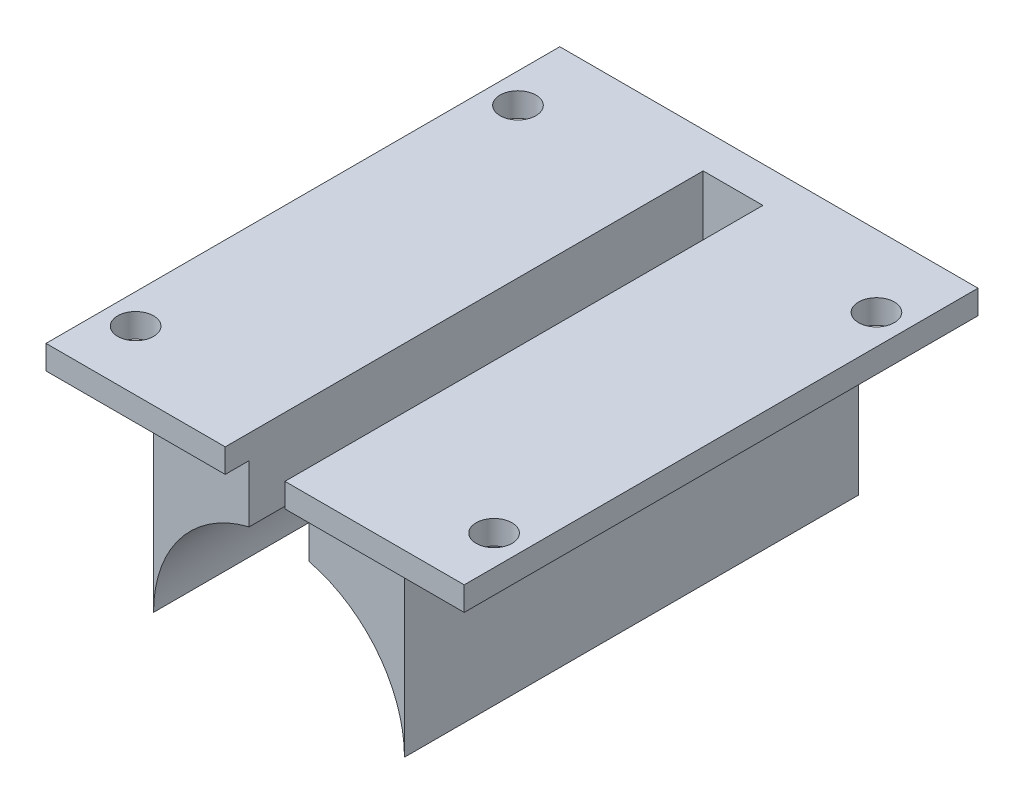
from build123d import *

# Parameters (mm, degrees)
SALIENTE_EXTRUIR1_DEPTH   = 38
SALIENTE_EXTRUIR1_2_DEPTH = 38
CROQUIS2_R                = 1.5
SALIENTE_EXTRUIR2_DEPTH   = 2
SALIENTE_EXTRUIR4_DEPTH   = 17
CROQUIS4_R                = 4
CORTAR_EXTRUIR2_DEPTH     = 17


with BuildPart() as part:
    # Croquis1 → Saliente-Extruir1 (new body)
    with BuildSketch(Plane.XY):
        with BuildLine():
            Line((10.5, 0), (10.5, 10.5))
            Line((10.5, 10.5), (10.5, 17))
            Line((10.5, 17), (2.5, 17))
            Line((2.5, 17), (2.5, 10.198039027))
            ThreePointArc((2.5, 10.198039027), (8.261355821, 6.480740698), (10.5, 0))
        make_face()
    extrude(amount=SALIENTE_EXTRUIR1_DEPTH)



with BuildPart() as body_2:
    # Croquis1 → Saliente-Extruir1 2 (new body)
    with BuildSketch(Plane.XY):
        with BuildLine():
            Line((-10.5, 0), (-10.5, 10.5))
            Line((-10.5, 10.5), (-10.5, 17))
            Line((-10.5, 17), (-2.5, 17))
            Line((-2.5, 17), (-2.5, 10.198039027))
            ThreePointArc((-2.5, 10.198039027), (-8.261355821, 6.480740698), (-10.5, 0))
        make_face()
    extrude(amount=SALIENTE_EXTRUIR1_2_DEPTH)


with BuildPart() as part_1:
    add(part.part)

    add(body_2.part)  # Saliente-Extruir2 merges body 2
    # Croquis2 → Saliente-Extruir2 (add)
    with BuildSketch(Plane(origin=(0, 17, 0), x_dir=(1, 0, 0), z_dir=(0, 1, 0))):
        Polygon((2.5, 0), (-2.5, 0), (-2.5, -40), (-12.5, -40), (-17.5, -40), (-17.5, 2), (-17.5, 3), (17.5, 3), (17.5, 2), (17.5, -40), (12.5, -40), (2.5, -40), align=None)
        with Locations((-15, -3)):
            Circle(CROQUIS2_R, mode=Mode.SUBTRACT)
        with Locations((15, -3)):
            Circle(CROQUIS2_R, mode=Mode.SUBTRACT)
        with Locations((15, -35)):
            Circle(CROQUIS2_R, mode=Mode.SUBTRACT)
        with Locations((-15, -35)):
            Circle(CROQUIS2_R, mode=Mode.SUBTRACT)
    extrude(amount=-SALIENTE_EXTRUIR2_DEPTH)

    # Croquis3 → Saliente-Extruir4 (add)
    with BuildSketch(Plane(origin=(0, 17, 0), x_dir=(1, 0, 0), z_dir=(0, 1, 0))):
        Polygon((0, 3), (-4, 3), (-4, 0), (3.996992923, 0), (3.996992923, 3), align=None)
    extrude(amount=-SALIENTE_EXTRUIR4_DEPTH)

    # Croquis4 → Cortar-Extruir2 (cut)
    with BuildSketch(Plane(origin=(0, 0, -3), x_dir=(-1, 0, 0), z_dir=(0, 0, -1))):
        Circle(CROQUIS4_R)
    extrude(amount=-CORTAR_EXTRUIR2_DEPTH, mode=Mode.SUBTRACT)


solid = part_1.part
